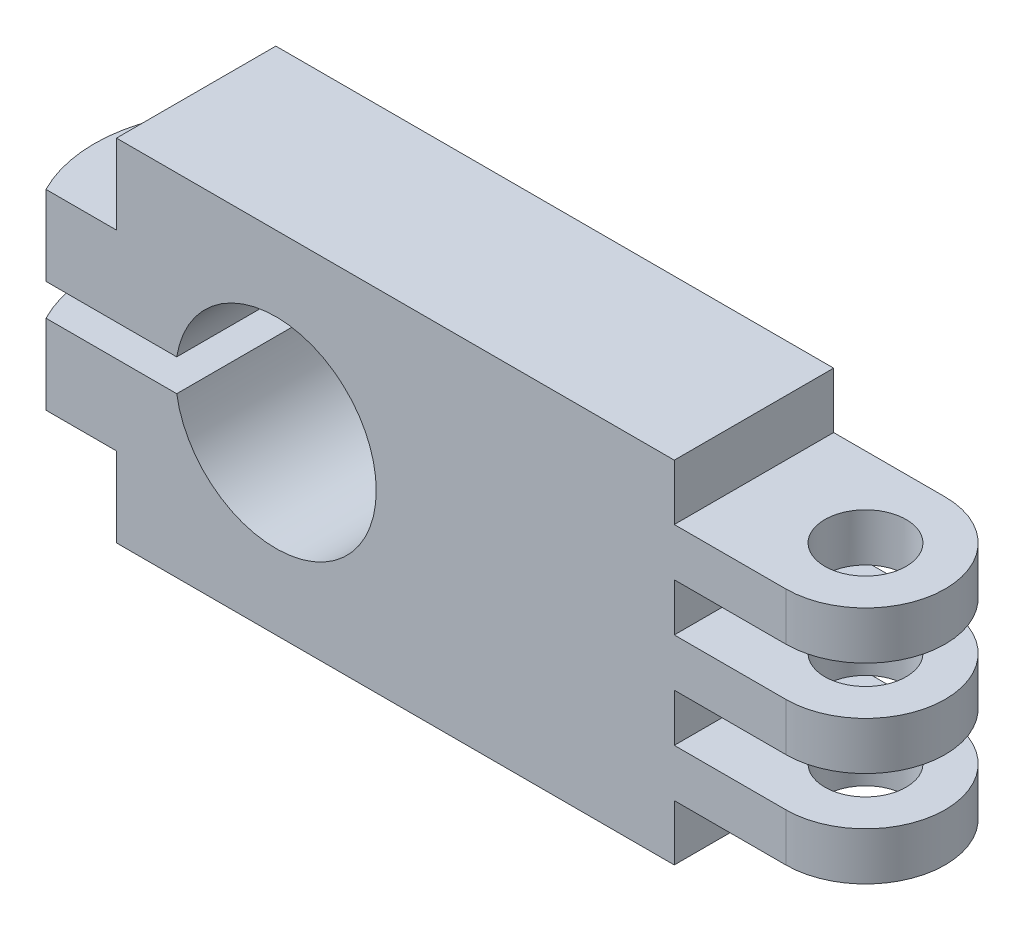
from build123d import *

# Parameters (mm, degrees)
EXTRUDE_1_DEPTH     = 10
SKETCH_2_R          = 2.55
CUT_EXTRUDE_1_DEPTH = 19
CUT_EXTRUDE_2_DEPTH = 19
SKETCH_5_W          = 10
SKETCH_5_H          = 2
CUT_EXTRUDE_4_DEPTH = 19
SKETCH_6_R          = 6.3
CUT_EXTRUDE_5_DEPTH = 19
CUT_EXTRUDE_6_DEPTH = 19
SKETCH_8_R          = 1
CUT_EXTRUDE_7_DEPTH = 18


with BuildPart() as part:
    # 草图1 → 凸台-拉伸1 (new body)
    with BuildSketch(Plane.XY):
        Polygon((0, 0), (35, 0), (35, -3.5), (47, -3.5), (47, -6.5), (35, -6.5), (35, -9.5), (47, -9.5), (47, -12.5), (35, -12.5), (35, -15.5), (47, -15.5), (47, -18.5), (35, -18.5), (35, -22), (0, -22), (0, -17), (-10, -17), (-10, -12), (0, -12), (0, -10), (-10, -10), (-10, -5), (0, -5), align=None)
    extrude(amount=EXTRUDE_1_DEPTH)

    # 草图2 → 切除-拉伸1 (cut)
    with BuildSketch(Plane(origin=(0, -3.5, 0), x_dir=(1, 0, 0), z_dir=(0, 1, 0))):
        with Locations((42, -5)):
            Circle(SKETCH_2_R)
    extrude(amount=-CUT_EXTRUDE_1_DEPTH, mode=Mode.SUBTRACT)

    # 草图3 → 切除-拉伸2 (cut)
    with BuildSketch(Plane(origin=(0, -3.5, 0), x_dir=(1, 0, 0), z_dir=(0, 1, 0))):
        with BuildLine():
            Line((42, 0), (35, 0))
            Line((35, 0), (35, 1.362905895))
            Line((35, 1.362905895), (53.328864927, 1.362905895))
            Line((53.328864927, 1.362905895), (53.328864927, -13.813237877))
            Line((53.328864927, -13.813237877), (35, -13.813237877))
            Line((35, -13.813237877), (35, -10))
            Line((35, -10), (42, -10))
            ThreePointArc((42, -10), (47, -5), (42, 0))
        make_face()
    extrude(amount=-CUT_EXTRUDE_2_DEPTH, mode=Mode.SUBTRACT)

    # 草图5 → 切除-拉伸4 (cut)
    with BuildSketch(Plane.XY.offset(10)):
        with Locations((5, -11)):
            Rectangle(SKETCH_5_W, SKETCH_5_H)
    extrude(amount=-CUT_EXTRUDE_4_DEPTH, mode=Mode.SUBTRACT)

    # 草图6 → 切除-拉伸5 (cut)
    with BuildSketch(Plane.XY.offset(10)):
        with Locations((10, -11)):
            Circle(SKETCH_6_R)
    extrude(amount=-CUT_EXTRUDE_5_DEPTH, mode=Mode.SUBTRACT)

    # 草图7 → 切除-拉伸6 (cut)
    with BuildSketch(Plane(origin=(0, -5, 0), x_dir=(1, 0, 0), z_dir=(0, 1, 0))):
        with BuildLine():
            Line((-4.422847497, -10), (-4.422847497, -16.245470045))
            Line((-4.422847497, -16.245470045), (-15.241663488, -16.245470045))
            Line((-15.241663488, -16.245470045), (-15.241663488, 3.326156632))
            Line((-15.241663488, 3.326156632), (-3, 3.326156632))
            Line((-3, 3.326156632), (-3, 0))
            ThreePointArc((-3, 0), (-5.308519262, -4.772757665), (-4.422847497, -10))
        make_face()
    extrude(amount=-CUT_EXTRUDE_6_DEPTH, mode=Mode.SUBTRACT)

    # 草图8 → 切除-拉伸7 (cut)
    with BuildSketch(Plane(origin=(0, -5, 0), x_dir=(1, 0, 0), z_dir=(0, 1, 0))):
        with Locations((-2.5, -6)):
            Circle(SKETCH_8_R)
    extrude(amount=-CUT_EXTRUDE_7_DEPTH, mode=Mode.SUBTRACT)


solid = part.part
